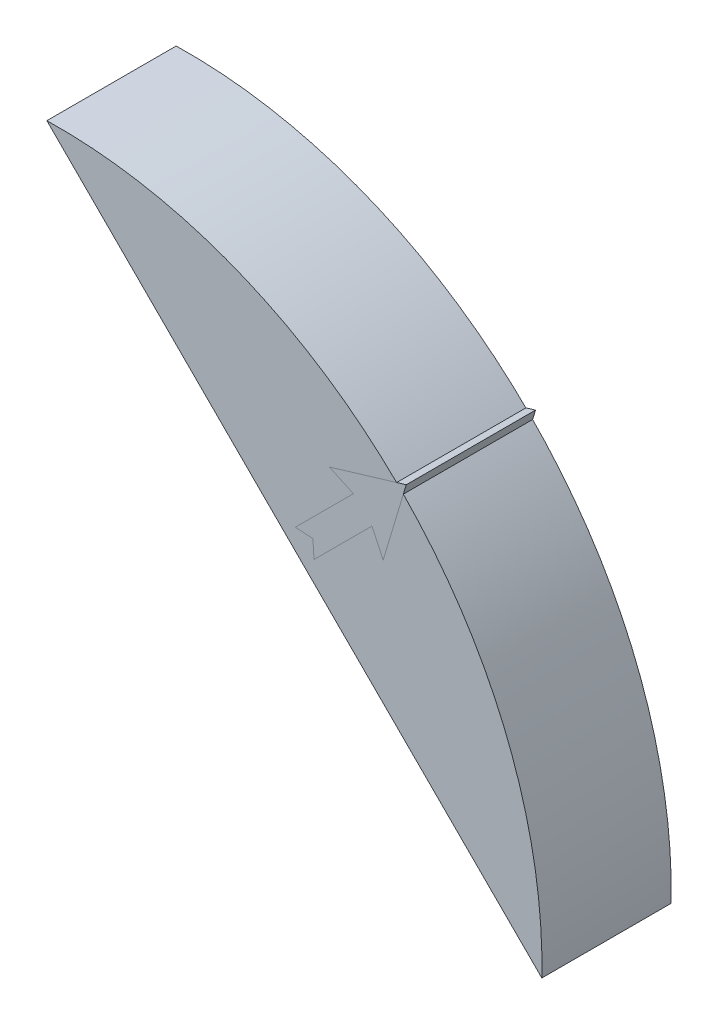
from build123d import *

# Parameters (mm, degrees)
FACE_2_DEPTH           = 2
CURVED_ALIGNMENT_DEPTH = 12.7
ARROW_CUT_START        = 1.5
ARROW_CUT_DEPTH        = 0.5
ARROW_EXTRUDE_START    = 1.5
ARROW_EXTRUDE_DEPTH    = 0.5
ARROW_TIP_START        = -12.7
ARROW_TIP_DEPTH        = 14.2


with BuildPart() as part:
    # main_features_sketch → face 2 (new body)
    with BuildSketch(Plane.XY):
        with BuildLine():
            Line((-1.191574198, 55.073110925), (55.073110925, -1.191574198))
            ThreePointArc((55.073110925, -1.191574198), (38.951684148, 38.951684148), (-1.191574198, 55.073110925))
        make_face()
    extrude(amount=FACE_2_DEPTH)

    # Sketch1_3 → curved_alignment (add)
    with BuildSketch(Plane.XY):
        with BuildLine():
            Line((-1.191574198, 55.073110925), (0.801588996, 53.079947731))
            ThreePointArc((0.801588996, 53.079947731), (19.932744129, 49.201718542), (36.368769629, 38.67086748))
            Line((36.368769629, 38.67086748), (38.568293544, 39.331337749))
            ThreePointArc((38.568293544, 39.331337749), (20.278206107, 51.217787467), (-1.191574198, 55.073110925))
        make_face()
        with BuildLine():
            Line((38.568293544, 39.331337749), (36.368769629, 38.67086748))
            ThreePointArc((36.368769629, 38.67086748), (37.537470586, 37.537470586), (38.67086748, 36.368769629))
            Line((38.67086748, 36.368769629), (39.331337749, 38.568293544))
            ThreePointArc((39.331337749, 38.568293544), (38.951684148, 38.951684148), (38.568293544, 39.331337749))
        make_face()
        with BuildLine():
            ThreePointArc((38.67086748, 36.368769629), (49.201718542, 19.932744129), (53.079947731, 0.801588996))
            Line((53.079947731, 0.801588996), (55.073110925, -1.191574198))
            ThreePointArc((55.073110925, -1.191574198), (51.217787467, 20.278206107), (39.331337749, 38.568293544))
            Line((39.331337749, 38.568293544), (38.67086748, 36.368769629))
        make_face()
    extrude(amount=-CURVED_ALIGNMENT_DEPTH)

    # Sketch1_4 → arrow_cut (cut)
    with BuildSketch(Plane.XY.offset(ARROW_CUT_START)):
        Polygon((27.056114693, 29.177435037), (33.64838329, 35.769703633), (30.929459928, 37.037558418), (39.65879093, 39.65879093), (37.037558418, 30.929459928), (35.769703633, 33.64838329), (29.177435037, 27.056114693), (29.052189212, 29.052189212), align=None)
    extrude(amount=ARROW_CUT_DEPTH, mode=Mode.SUBTRACT)


with BuildPart() as body_2:
    # Sketch1_5 → arrow_extrude (new body)
    with BuildSketch(Plane.XY.offset(ARROW_EXTRUDE_START)):
        Polygon((27.056114693, 29.177435037), (33.64838329, 35.769703633), (30.929459928, 37.037558418), (39.65879093, 39.65879093), (37.037558418, 30.929459928), (35.769703633, 33.64838329), (29.177435037, 27.056114693), (29.052189212, 29.052189212), align=None)
    extrude(amount=ARROW_EXTRUDE_DEPTH)

    # main_features_sketch_6 → arrow_tip (add)
    with BuildSketch(Plane.XY.offset(ARROW_TIP_START)):
        with BuildLine():
            Line((39.65879093, 39.65879093), (38.568293544, 39.331337749))
            ThreePointArc((38.568293544, 39.331337749), (38.951684148, 38.951684148), (39.331337749, 38.568293544))
            Line((39.331337749, 38.568293544), (39.65879093, 39.65879093))
        make_face()
    extrude(amount=ARROW_TIP_DEPTH)


solid = Compound([part.part, body_2.part])
